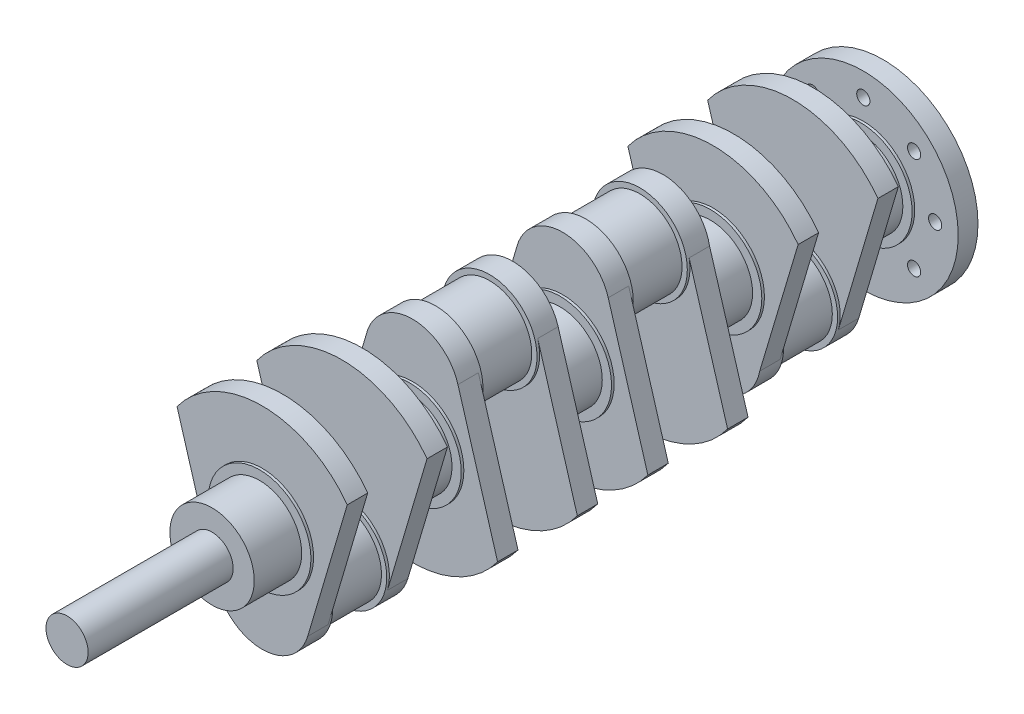
from build123d import *

# Parameters (mm, degrees)
SKETCH1_R            = 72
SKETCH1_R_2          = 5
BOSS_EXTRUDE1_DEPTH  = 15
SKETCH2_R            = 39
BOSS_EXTRUDE2_DEPTH  = 2
SKETCH3_R            = 32
BOSS_EXTRUDE3_DEPTH  = 36
SKETCH4_R            = 80
BOSS_EXTRUDE4_DEPTH  = 15.5
CUT_EXTRUDE2_DEPTH   = 15.5
SKETCH7_R            = 39
SKETCH7_R_2          = 32
BOSS_EXTRUDE6_DEPTH  = 2
SKETCH9_R            = 36
BOSS_EXTRUDE7_DEPTH  = 2
SKETCH10_R           = 32
BOSS_EXTRUDE8_DEPTH  = 41
SKETCH11_R           = 36
BOSS_EXTRUDE9_DEPTH  = 2
BOSS_EXTRUDE10_DEPTH = 15.5
SKETCH14_R           = 39
BOSS_EXTRUDE11_DEPTH = 2
SKETCH15_R           = 32
BOSS_EXTRUDE12_DEPTH = 34
SKETCH16_R           = 39
BOSS_EXTRUDE13_DEPTH = 2
BOSS_EXTRUDE14_DEPTH = 15.5
SKETCH18_R           = 36
BOSS_EXTRUDE15_DEPTH = 2
SKETCH19_R           = 32
BOSS_EXTRUDE16_DEPTH = 41
SKETCH20_R           = 36
BOSS_EXTRUDE17_DEPTH = 2
BOSS_EXTRUDE18_DEPTH = 15.5
SKETCH22_R           = 39
BOSS_EXTRUDE19_DEPTH = 2
SKETCH23_R           = 32
BOSS_EXTRUDE20_DEPTH = 34
SKETCH24_R           = 39
BOSS_EXTRUDE21_DEPTH = 2
BOSS_EXTRUDE22_DEPTH = 15.5
SKETCH29_R           = 36
BOSS_EXTRUDE26_DEPTH = 2
SKETCH30_R           = 32
BOSS_EXTRUDE27_DEPTH = 41
SKETCH31_R           = 36
BOSS_EXTRUDE28_DEPTH = 2
BOSS_EXTRUDE29_DEPTH = 15.5
SKETCH33_R           = 39
BOSS_EXTRUDE30_DEPTH = 2
SKETCH34_R           = 32
BOSS_EXTRUDE31_DEPTH = 34
SKETCH35_R           = 39
BOSS_EXTRUDE32_DEPTH = 2
BOSS_EXTRUDE33_DEPTH = 15.5
SKETCH37_R           = 36
BOSS_EXTRUDE34_DEPTH = 2
SKETCH38_R           = 32
BOSS_EXTRUDE35_DEPTH = 41
SKETCH39_R           = 36
BOSS_EXTRUDE36_DEPTH = 2
BOSS_EXTRUDE37_DEPTH = 15.5
SKETCH43_R           = 39
BOSS_EXTRUDE38_DEPTH = 2
SKETCH44_R           = 32
BOSS_EXTRUDE39_DEPTH = 36
SKETCH45_R           = 16
BOSS_EXTRUDE40_DEPTH = 110


with BuildPart() as part:
    # Sketch1 → Boss-Extrude1 (new body)
    with BuildSketch(Plane.XY):
        Circle(SKETCH1_R)
        with Locations((0, 54.5)):
            Circle(SKETCH1_R_2, mode=Mode.SUBTRACT)
        with Locations((38.537319575, 38.537319575)):
            Circle(SKETCH1_R_2, mode=Mode.SUBTRACT)
        with Locations((54.5, 0)):
            Circle(SKETCH1_R_2, mode=Mode.SUBTRACT)
        with Locations((38.537319575, -38.537319575)):
            Circle(SKETCH1_R_2, mode=Mode.SUBTRACT)
        with Locations((0, -54.5)):
            Circle(SKETCH1_R_2, mode=Mode.SUBTRACT)
        with Locations((-38.537319575, -38.537319575)):
            Circle(SKETCH1_R_2, mode=Mode.SUBTRACT)
        with Locations((-54.5, 0)):
            Circle(SKETCH1_R_2, mode=Mode.SUBTRACT)
        with Locations((-38.537319575, 38.537319575)):
            Circle(SKETCH1_R_2, mode=Mode.SUBTRACT)
    extrude(amount=BOSS_EXTRUDE1_DEPTH)

    # Sketch2 → Boss-Extrude2 (add)
    with BuildSketch(Plane.XY.offset(15)):
        Circle(SKETCH2_R)
    extrude(amount=BOSS_EXTRUDE2_DEPTH)

    # Sketch3 → Boss-Extrude3 (add)
    with BuildSketch(Plane.XY.offset(17)):
        Circle(SKETCH3_R)
    extrude(amount=BOSS_EXTRUDE3_DEPTH)

    # Sketch4 → Boss-Extrude4 (add)
    with BuildSketch(Plane.XY.offset(53)):
        Circle(SKETCH4_R)
    extrude(amount=BOSS_EXTRUDE4_DEPTH)

    # Sketch5 → Cut-Extrude2 (cut)
    with BuildSketch(Plane.XY.offset(68.5)):
        with BuildLine():
            ThreePointArc((-7.7e-08, -80), (-21.539685652, -72.845137234), (-34.517510455, -54.224552409))
            Line((-34.517510455, -54.224552409), (-64.569893475, 47.23059238))
            ThreePointArc((-64.569893475, 47.23059238), (-71.33879518, -36.204644761), (-7.7e-08, -80))
        make_face()
        with BuildLine():
            ThreePointArc((34.517510455, -54.224552409), (21.53968559, -72.84513728), (-7.7e-08, -80))
            ThreePointArc((-7.7e-08, -80), (56.568542468, -56.568542522), (80, 0))
            ThreePointArc((80, 0), (76.044695667, 24.843595975), (64.569893475, 47.23059238))
            Line((64.569893475, 47.23059238), (34.517510455, -54.224552409))
        make_face()
    extrude(amount=-CUT_EXTRUDE2_DEPTH, mode=Mode.SUBTRACT)

    # Sketch7 → Boss-Extrude6 (add)
    with BuildSketch(Plane(origin=(0, 0, 53), x_dir=(-1, 0, 0), z_dir=(0, 0, -1))):
        Circle(SKETCH7_R)
        Circle(SKETCH7_R_2, mode=Mode.SUBTRACT)
    extrude(amount=BOSS_EXTRUDE6_DEPTH)

    # Sketch9 → Boss-Extrude7 (add)
    with BuildSketch(Plane.XY.offset(68.5)):
        with Locations((0, -44)):
            Circle(SKETCH9_R)
    extrude(amount=BOSS_EXTRUDE7_DEPTH)

    # Sketch10 → Boss-Extrude8 (add)
    with BuildSketch(Plane.XY.offset(70.5)):
        with Locations((0, -44)):
            Circle(SKETCH10_R)
    extrude(amount=BOSS_EXTRUDE8_DEPTH)

    # Sketch11 → Boss-Extrude9 (add)
    with BuildSketch(Plane.XY.offset(111.5)):
        with Locations((0, -44)):
            Circle(SKETCH11_R)
    extrude(amount=BOSS_EXTRUDE9_DEPTH)

    # Sketch13 → Boss-Extrude10 (add)
    with BuildSketch(Plane.XY.offset(113.5)):
        with BuildLine():
            Line((-64.569893475, 47.23059238), (-35.103878052, -51.982339614))
            ThreePointArc((-35.103878052, -51.982339614), (0.703146821, -79.993132464), (35.38885459, -50.605222996))
            Line((35.38885459, -50.605222996), (64.569893475, 47.23059238))
            ThreePointArc((64.569893475, 47.23059238), (0, 80), (-64.569893475, 47.23059238))
        make_face()
    extrude(amount=BOSS_EXTRUDE10_DEPTH)

    # Sketch14 → Boss-Extrude11 (add)
    with BuildSketch(Plane.XY.offset(129)):
        Circle(SKETCH14_R)
    extrude(amount=BOSS_EXTRUDE11_DEPTH)

    # Sketch15 → Boss-Extrude12 (add)
    with BuildSketch(Plane.XY.offset(131)):
        Circle(SKETCH15_R)
    extrude(amount=BOSS_EXTRUDE12_DEPTH)

    # Sketch16 → Boss-Extrude13 (add)
    with BuildSketch(Plane.XY.offset(165)):
        Circle(SKETCH16_R)
    extrude(amount=BOSS_EXTRUDE13_DEPTH)

    # Sketch17 → Boss-Extrude14 (add)
    with BuildSketch(Plane.XY.offset(167)):
        with BuildLine():
            Line((-64.569893475, -47.23059238), (-35.103878052, 51.982339614))
            ThreePointArc((-35.103878052, 51.982339614), (0.703146821, 79.993132464), (35.38885459, 50.605222996))
            Line((35.38885459, 50.605222996), (64.569893475, -47.23059238))
            ThreePointArc((64.569893475, -47.23059238), (0, -80), (-64.569893475, -47.23059238))
        make_face()
    extrude(amount=BOSS_EXTRUDE14_DEPTH)

    # Sketch18 → Boss-Extrude15 (add)
    with BuildSketch(Plane.XY.offset(182.5)):
        with Locations((0, 44)):
            Circle(SKETCH18_R)
    extrude(amount=BOSS_EXTRUDE15_DEPTH)

    # Sketch19 → Boss-Extrude16 (add)
    with BuildSketch(Plane.XY.offset(184.5)):
        with Locations((0, 44)):
            Circle(SKETCH19_R)
    extrude(amount=BOSS_EXTRUDE16_DEPTH)

    # Sketch20 → Boss-Extrude17 (add)
    with BuildSketch(Plane.XY.offset(225.5)):
        with Locations((0, 44)):
            Circle(SKETCH20_R)
    extrude(amount=BOSS_EXTRUDE17_DEPTH)

    # Sketch21 → Boss-Extrude18 (add)
    with BuildSketch(Plane.XY.offset(227.5)):
        with BuildLine():
            Line((-34.94290999, 52.659852274), (-64.569893475, -47.23059238))
            ThreePointArc((-64.569893475, -47.23059238), (0, -80), (64.569893475, -47.23059238))
            Line((64.569893475, -47.23059238), (34.517510455, 54.224552409))
            ThreePointArc((34.517510455, 54.224552409), (35.627449926, 49.165734392), (36, 44))
            ThreePointArc((36, 44), (-4.362066044, 8.265249688), (-34.94290999, 52.659852274))
        make_face()
        with BuildLine():
            ThreePointArc((0, 80), (-22.183837789, 72.352730749), (-34.94290999, 52.659852274))
            ThreePointArc((-34.94290999, 52.659852274), (-4.362066044, 8.265249688), (36, 44))
            ThreePointArc((36, 44), (35.627449926, 49.165734392), (34.517510455, 54.224552409))
            ThreePointArc((34.517510455, 54.224552409), (21.539685621, 72.845137257), (0, 80))
        make_face()
    extrude(amount=BOSS_EXTRUDE18_DEPTH)

    # Sketch22 → Boss-Extrude19 (add)
    with BuildSketch(Plane.XY.offset(243)):
        Circle(SKETCH22_R)
    extrude(amount=BOSS_EXTRUDE19_DEPTH)

    # Sketch23 → Boss-Extrude20 (add)
    with BuildSketch(Plane.XY.offset(245)):
        Circle(SKETCH23_R)
    extrude(amount=BOSS_EXTRUDE20_DEPTH)

    # Sketch24 → Boss-Extrude21 (add)
    with BuildSketch(Plane.XY.offset(279)):
        Circle(SKETCH24_R)
    extrude(amount=BOSS_EXTRUDE21_DEPTH)

    # Sketch25 → Boss-Extrude22 (add)
    with BuildSketch(Plane.XY.offset(281)):
        with BuildLine():
            Line((64.569893475, -47.23059238), (34.517510455, 54.224552409))
            ThreePointArc((34.517510455, 54.224552409), (0, 80), (-34.517510455, 54.224552409))
            Line((-34.517510455, 54.224552409), (-64.569893475, -47.23059238))
            ThreePointArc((-64.569893475, -47.23059238), (0, -80), (64.569893475, -47.23059238))
        make_face()
    extrude(amount=BOSS_EXTRUDE22_DEPTH)

    # Sketch29 → Boss-Extrude26 (add)
    with BuildSketch(Plane.XY.offset(296.5)):
        with Locations((0, 44)):
            Circle(SKETCH29_R)
    extrude(amount=BOSS_EXTRUDE26_DEPTH)

    # Sketch30 → Boss-Extrude27 (add)
    with BuildSketch(Plane.XY.offset(298.5)):
        with Locations((0, 44)):
            Circle(SKETCH30_R)
    extrude(amount=BOSS_EXTRUDE27_DEPTH)

    # Sketch31 → Boss-Extrude28 (add)
    with BuildSketch(Plane.XY.offset(339.5)):
        with Locations((0, 44)):
            Circle(SKETCH31_R)
    extrude(amount=BOSS_EXTRUDE28_DEPTH)

    # Sketch32 → Boss-Extrude29 (add)
    with BuildSketch(Plane.XY.offset(341.5)):
        with BuildLine():
            Line((-35.001162126, 52.421321146), (-64.569893475, -47.23059238))
            ThreePointArc((-64.569893475, -47.23059238), (0, -80), (64.569893475, -47.23059238))
            Line((64.569893475, -47.23059238), (34.517510455, 54.224552409))
            ThreePointArc((34.517510455, 54.224552409), (0.950243427, 79.987456668), (-33.929832299, 56.031894288))
            Line((-33.929832299, 56.031894288), (-35.001162126, 52.421321146))
        make_face()
    extrude(amount=BOSS_EXTRUDE29_DEPTH)

    # Sketch33 → Boss-Extrude30 (add)
    with BuildSketch(Plane.XY.offset(357)):
        Circle(SKETCH33_R)
    extrude(amount=BOSS_EXTRUDE30_DEPTH)

    # Sketch34 → Boss-Extrude31 (add)
    with BuildSketch(Plane.XY.offset(359)):
        Circle(SKETCH34_R)
    extrude(amount=BOSS_EXTRUDE31_DEPTH)

    # Sketch35 → Boss-Extrude32 (add)
    with BuildSketch(Plane.XY.offset(393)):
        Circle(SKETCH35_R)
    extrude(amount=BOSS_EXTRUDE32_DEPTH)

    # Sketch36 → Boss-Extrude33 (add)
    with BuildSketch(Plane.XY.offset(395)):
        with BuildLine():
            Line((-64.569893475, 47.23059238), (-35.103878052, -51.982339614))
            ThreePointArc((-35.103878052, -51.982339614), (-1.158808135, -79.981344662), (34.517510455, -54.224552409))
            Line((34.517510455, -54.224552409), (64.569893475, 47.23059238))
            ThreePointArc((64.569893475, 47.23059238), (0, 80), (-64.569893475, 47.23059238))
        make_face()
    extrude(amount=BOSS_EXTRUDE33_DEPTH)

    # Sketch37 → Boss-Extrude34 (add)
    with BuildSketch(Plane.XY.offset(410.5)):
        with Locations((0, -44)):
            Circle(SKETCH37_R)
    extrude(amount=BOSS_EXTRUDE34_DEPTH)

    # Sketch38 → Boss-Extrude35 (add)
    with BuildSketch(Plane.XY.offset(412.5)):
        with Locations((0, -44)):
            Circle(SKETCH38_R)
    extrude(amount=BOSS_EXTRUDE35_DEPTH)

    # Sketch39 → Boss-Extrude36 (add)
    with BuildSketch(Plane.XY.offset(453.5)):
        with Locations((0, -44)):
            Circle(SKETCH39_R)
    extrude(amount=BOSS_EXTRUDE36_DEPTH)

    # Sketch42 → Boss-Extrude37 (add)
    with BuildSketch(Plane.XY.offset(455.5)):
        with BuildLine():
            Line((-64.569893475, 47.23059238), (-35.103878052, -51.982339614))
            ThreePointArc((-35.103878052, -51.982339614), (-1.158808135, -79.981344662), (34.517510455, -54.224552409))
            Line((34.517510455, -54.224552409), (64.569893475, 47.23059238))
            ThreePointArc((64.569893475, 47.23059238), (0, 80), (-64.569893475, 47.23059238))
        make_face()
    extrude(amount=BOSS_EXTRUDE37_DEPTH)

    # Sketch43 → Boss-Extrude38 (add)
    with BuildSketch(Plane.XY.offset(471)):
        Circle(SKETCH43_R)
    extrude(amount=BOSS_EXTRUDE38_DEPTH)

    # Sketch44 → Boss-Extrude39 (add)
    with BuildSketch(Plane.XY.offset(473)):
        Circle(SKETCH44_R)
    extrude(amount=BOSS_EXTRUDE39_DEPTH)

    # Sketch45 → Boss-Extrude40 (add)
    with BuildSketch(Plane.XY.offset(509)):
        Circle(SKETCH45_R)
    extrude(amount=BOSS_EXTRUDE40_DEPTH)


solid = part.part
